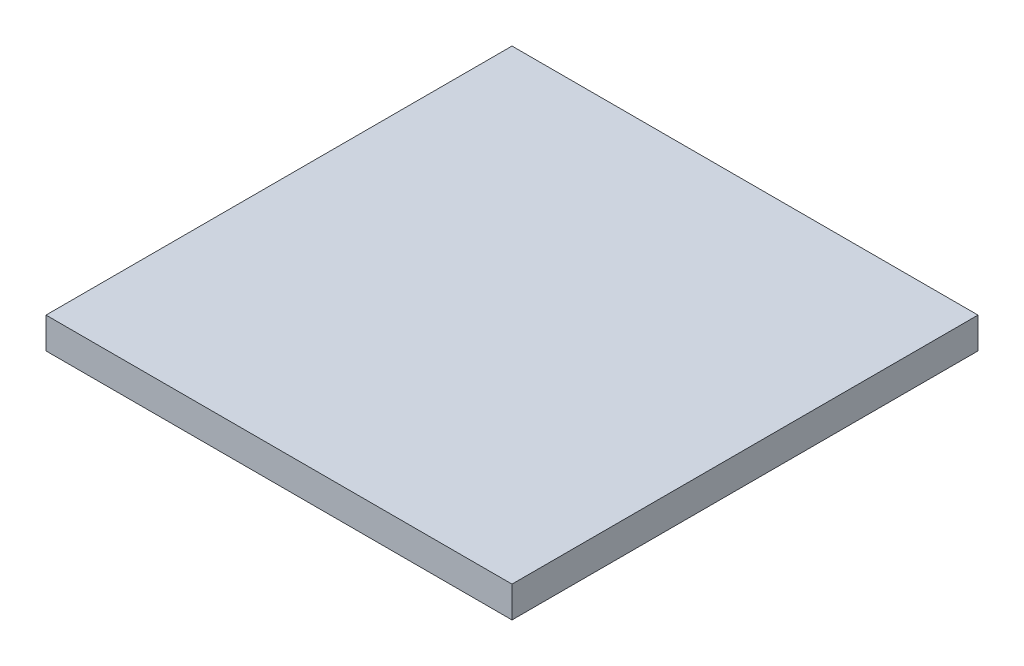
from build123d import *

# Parameters (mm, degrees)
SKETCH1_W           = 1524
SKETCH1_H           = 1524
BOSS_EXTRUDE1_DEPTH = 101.6


with BuildPart() as part:
    # Sketch1 → Boss-Extrude1 (new body)
    with BuildSketch(Plane(origin=(0, 0, 0), x_dir=(1, 0, 0), z_dir=(0, 1, 0))):
        with Locations((762, 762)):
            Rectangle(SKETCH1_W, SKETCH1_H)
    extrude(amount=BOSS_EXTRUDE1_DEPTH)


solid = part.part
